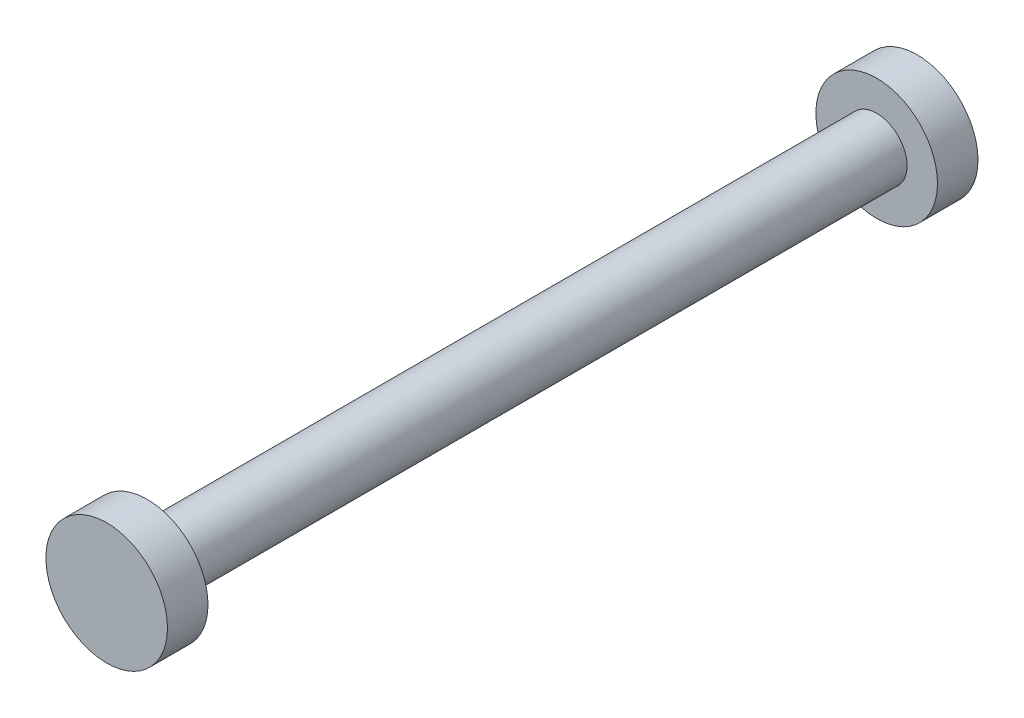
from build123d import *

# Parameters (mm, degrees)
SKETCH1_R           = 1.905
BOSS_EXTRUDE1_DEPTH = 45.72
SKETCH4_R           = 3.81
BOSS_EXTRUDE2_DEPTH = 2.54


with BuildPart() as part:
    # Sketch1 → Boss-Extrude1 (new body)
    with BuildSketch(Plane.XY):
        Circle(SKETCH1_R)
    extrude(amount=BOSS_EXTRUDE1_DEPTH)

    # Sketch4 → Boss-Extrude2 (add)
    with BuildSketch(Plane.XY.offset(45.72)):
        Circle(SKETCH4_R)
    boss_extrude2 = extrude(amount=BOSS_EXTRUDE2_DEPTH)

    # Mirror1: Boss-Extrude2 across plane
    add(boss_extrude2.mirror(Plane.XY.offset(22.86)))


solid = part.part
